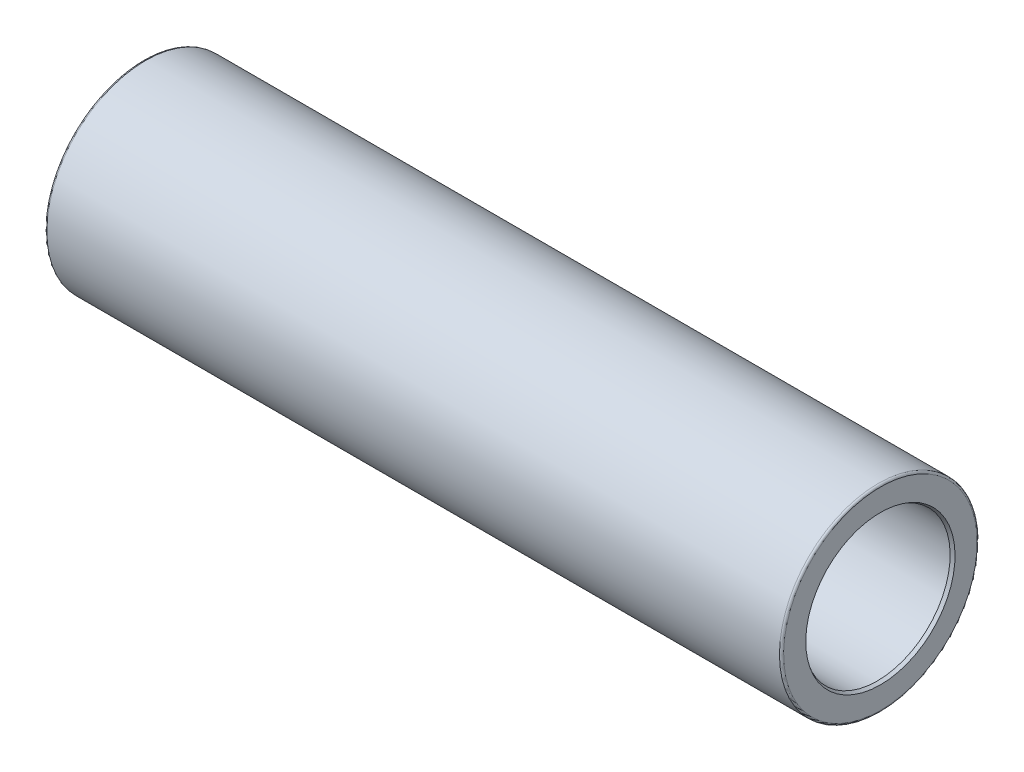
from build123d import *


with BuildPart() as part:
    # Sketch1 → Base-Revolve (revolve)
    with BuildSketch(Plane.XY):
        with BuildLine():
            Line((-177, 35), (-177, 46.5))
            ThreePointArc((-177, 46.5), (-176.707106781, 47.207106781), (-176, 47.5))
            Line((-176, 47.5), (176, 47.5))
            ThreePointArc((176, 47.5), (176.707106781, 47.207106781), (177, 46.5))
            Line((177, 46.5), (177, 35))
            Line((177, 35), (110.962610506, 35))
            Line((110.962610506, 35), (109, 36))
            Line((109, 36), (107, 36))
            Line((107, 36), (107, 34))
            Line((107, 34), (97.176326981, 34))
            ThreePointArc((97.176326981, 34), (97.002678803, 34.015192247), (96.834306837, 34.060307379))
            Line((96.834306837, 34.060307379), (87.549522195, 37.439692621))
            ThreePointArc((87.549522195, 37.439692621), (87.381150229, 37.484807753), (87.207502051, 37.5))
            Line((87.207502051, 37.5), (-87.207502051, 37.5))
            ThreePointArc((-87.207502051, 37.5), (-87.381150229, 37.484807753), (-87.549522195, 37.439692621))
            Line((-87.549522195, 37.439692621), (-96.834306837, 34.060307379))
            ThreePointArc((-96.834306837, 34.060307379), (-97.002678803, 34.015192247), (-97.176326981, 34))
            Line((-97.176326981, 34), (-107, 34))
            Line((-107, 34), (-107, 36))
            Line((-107, 36), (-109, 36))
            Line((-109, 36), (-110.962610506, 35))
            Line((-110.962610506, 35), (-177, 35))
        make_face()
    revolve(axis=Axis((-177, 0, 0), (1, 0, 0)))

    # Sketch5 → Reifning 2.5 x 30 gr (revolve, cut)
    with BuildSketch(Plane.XY):
        Polygon((-177, 35), (-177, 35.866025404), (-175.5, 35), align=None)
        Polygon((177, 35), (175.5, 35), (177, 35.866025404), align=None)
    revolve(axis=Axis((0, 0, 0), (1, 0, 0)), mode=Mode.SUBTRACT)


solid = part.part
